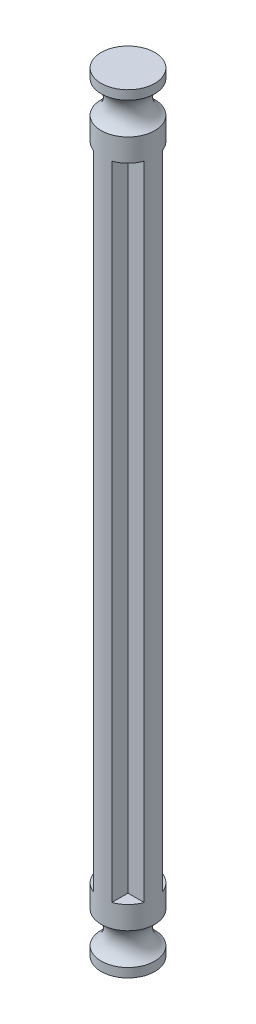
from build123d import *

# Parameters (mm, degrees)
EXTRUDE_2_DEPTH = 70.64


with BuildPart() as part:
    # 草图1 → 凸台-拉伸2 (new body)
    with BuildSketch(Plane(origin=(0, 0, 0), x_dir=(1, 0, 0), z_dir=(0, 1, 0))):
        with BuildLine():
            Line((1, 1), (1, 2.775338))
            ThreePointArc((1, 2.775338), (0, 2.95), (-1, 2.775338))
            Line((-1, 2.775338), (-1, 1))
            Line((-1, 1), (-2.775338, 1))
            ThreePointArc((-2.775338, 1), (-2.95, 0), (-2.775338, -1))
            Line((-2.775338, -1), (-1, -1))
            Line((-1, -1), (-1, -2.775338))
            ThreePointArc((-1, -2.775338), (0, -2.95), (1, -2.775338))
            Line((1, -2.775338), (1, -1))
            Line((1, -1), (2.775338, -1))
            ThreePointArc((2.775338, -1), (2.95, 0), (2.775338, 1))
            Line((2.775338, 1), (1, 1))
        make_face()
    extrude(amount=EXTRUDE_2_DEPTH)

    # 草图3 → 旋转3 (revolve)
    with BuildSketch(Plane(origin=(0, 0, 0), x_dir=(0, 0, -1), z_dir=(1, 0, 0))):
        with BuildLine():
            Line((0, 70.64), (0, 77.64))
            Line((0, 77.64), (2.95, 77.64))
            Line((2.95, 77.64), (2.95, 76.64))
            ThreePointArc((2.95, 76.64), (1.918246, 74.89), (2.95, 73.14))
            Line((2.95, 73.14), (2.95, 70.64))
            Line((2.95, 70.64), (0, 70.64))
        make_face()
        with BuildLine():
            Line((0, 0), (0, -7))
            Line((0, -7), (2.95, -7))
            Line((2.95, -7), (2.95, -6))
            ThreePointArc((2.95, -6), (1.918246, -4.25), (2.95, -2.5))
            Line((2.95, -2.5), (2.95, 0))
            Line((2.95, 0), (0, 0))
        make_face()
    revolve(axis=Axis((0, 0, 0), (0, -1, 0)))


solid = part.part
